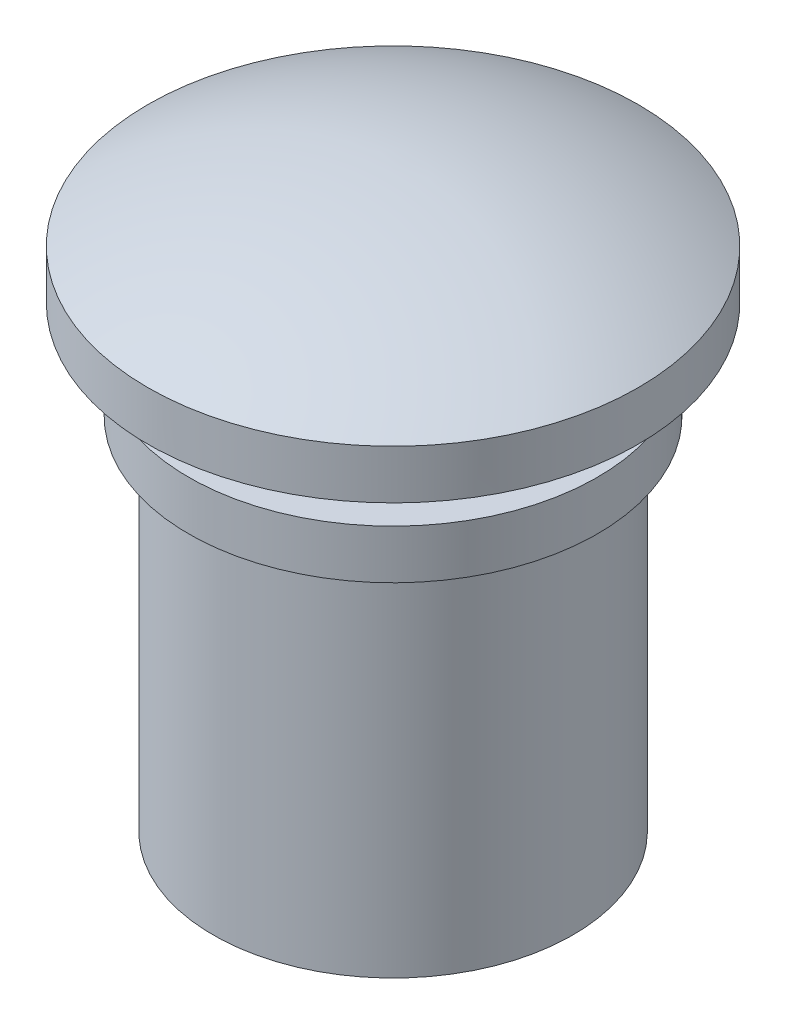
from build123d import *


with BuildPart() as part:
    # Sketch1 → Revolve1 (revolve)
    with BuildSketch(Plane(origin=(0, 0, 0), x_dir=(0, 0, -1), z_dir=(1, 0, 0))):
        with BuildLine():
            Line((0, 0), (0, -22))
            Line((0, -22), (11, -22))
            Line((11, -22), (11, 0))
            Line((11, 0), (12.5, 0))
            Line((12.5, 0), (12.5, 3))
            Line((12.5, 3), (8, 3))
            Line((8, 3), (8, 6))
            Line((8, 6), (15, 6))
            Line((15, 6), (15, 9))
            ThreePointArc((15, 9), (7.762087348, 11.982827555), (0, 13))
            Line((0, 13), (0, 0))
        make_face()
    revolve(axis=Axis((0, 0, 0), (0, 1, 0)))


solid = part.part
